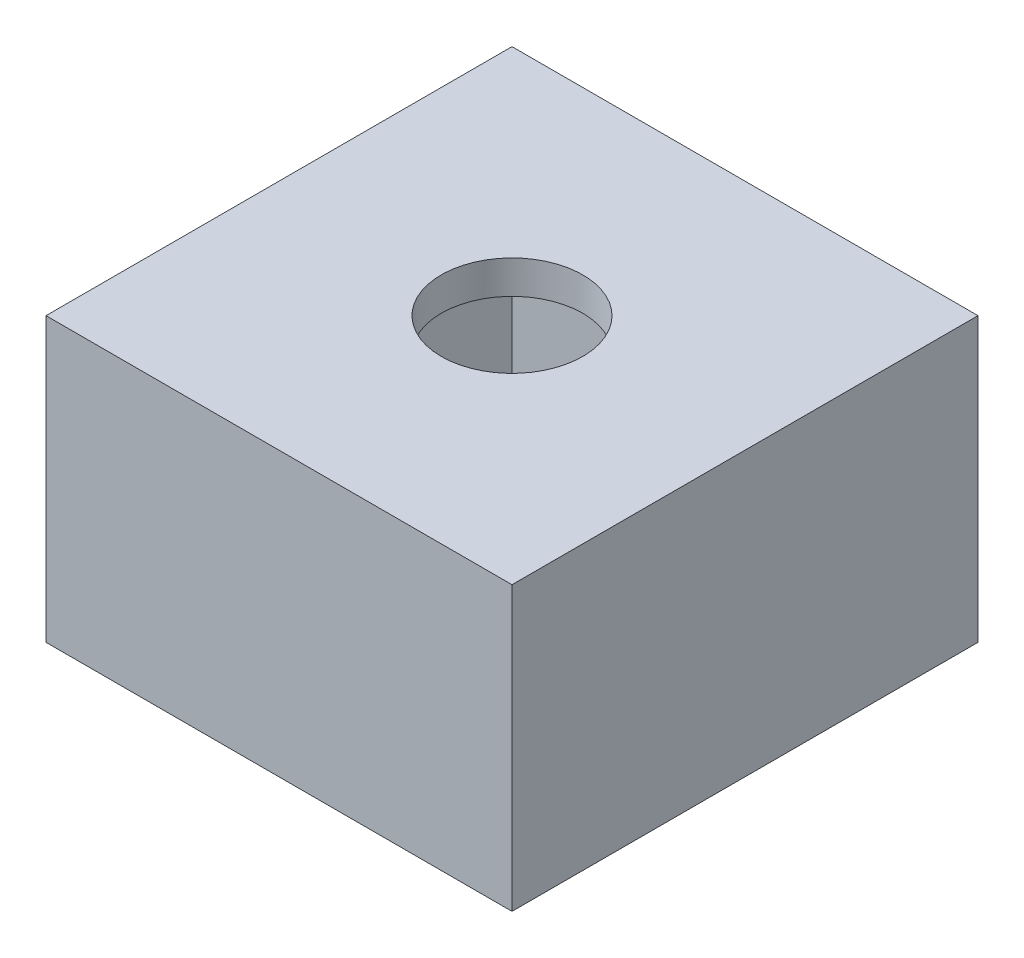
from build123d import *

# Parameters (mm, degrees)
SKETCH1_W           = 28
SKETCH1_H           = 28
SKETCH1_W_2         = 24
SKETCH1_H_2         = 24
BOSS_EXTRUDE1_DEPTH = 15
SKETCH2_W           = 28
SKETCH2_H           = 28
BOSS_EXTRUDE2_DEPTH = 2
CUT_EXTRUDE1_REACH  = 19
SKETCH3_R           = 4.25


with BuildPart() as part:
    # Sketch1 → Boss-Extrude1 (new body)
    with BuildSketch(Plane(origin=(0, 0, 0), x_dir=(1, 0, 0), z_dir=(0, 1, 0))):
        Rectangle(SKETCH1_W, SKETCH1_H)
        Rectangle(SKETCH1_W_2, SKETCH1_H_2, mode=Mode.SUBTRACT)
    extrude(amount=BOSS_EXTRUDE1_DEPTH)

    # Sketch2 → Boss-Extrude2 (add)
    with BuildSketch(Plane(origin=(0, 15, 0), x_dir=(1, 0, 0), z_dir=(0, 1, 0))):
        Rectangle(SKETCH2_W, SKETCH2_H)
    extrude(amount=BOSS_EXTRUDE2_DEPTH)

    # Sketch3 → Cut-Extrude1 (cut, up to next)
    with BuildSketch(Plane(origin=(0, 17, 0), x_dir=(1, 0, 0), z_dir=(0, 1, 0)), mode=Mode.PRIVATE) as cut_extrude1_sk1:
        Circle(SKETCH3_R)
    cut_extrude1_tool1 = extrude(cut_extrude1_sk1.sketch, amount=-CUT_EXTRUDE1_REACH, mode=Mode.PRIVATE) & part.part
    add(cut_extrude1_tool1.solids().sort_by_distance((0, 17, 0))[0], mode=Mode.SUBTRACT)


solid = part.part
